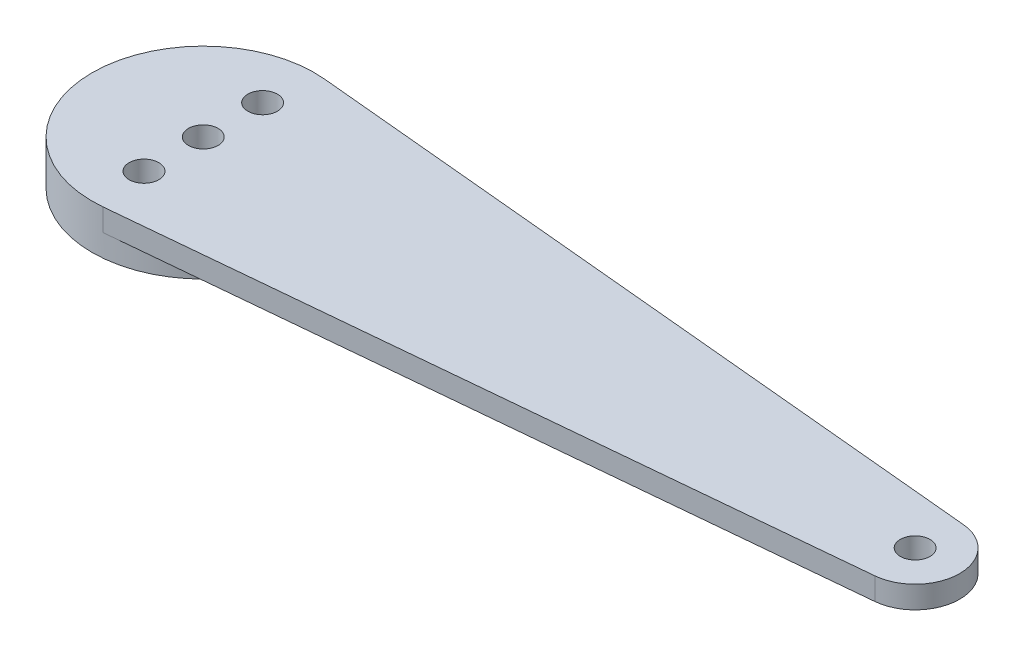
from build123d import *

# Parameters (mm, degrees)
SKETCH1_R           = 2
BOSS_EXTRUDE1_DEPTH = 3
BOSS_EXTRUDE2_START = -3
SKETCH1_3_R         = 2
BOSS_EXTRUDE2_DEPTH = 3


with BuildPart() as part:
    # Sketch1 → Boss-Extrude1 (new body)
    with BuildSketch(Plane(origin=(0, 0, 0), x_dir=(1, 0, 0), z_dir=(0, 1, 0))):
        with BuildLine():
            ThreePointArc((0.5625, -5.973574621), (6, 0), (0.5625, 5.973574621))
            Line((0.5625, 5.973574621), (-94.59375, 14.933936552))
            ThreePointArc((-94.59375, 14.933936552), (-111, 0), (-94.59375, -14.933936552))
            Line((-94.59375, -14.933936552), (0.5625, -5.973574621))
        make_face()
        Circle(SKETCH1_R, mode=Mode.SUBTRACT)
        with Locations((-96, 0)):
            Circle(SKETCH1_R, mode=Mode.SUBTRACT)
        with Locations((-96, 8)):
            Circle(SKETCH1_R, mode=Mode.SUBTRACT)
        with Locations((-96, -8)):
            Circle(SKETCH1_R, mode=Mode.SUBTRACT)
    extrude(amount=BOSS_EXTRUDE1_DEPTH)

    # Sketch1_3 → Boss-Extrude2 (add)
    with BuildSketch(Plane(origin=(0, 0, 0), x_dir=(1, 0, 0), z_dir=(0, 1, 0)).offset(BOSS_EXTRUDE2_START)):
        with BuildLine():
            ThreePointArc((-81, 0), (-84.907350407, 10.097184013), (-94.59375, 14.933936552))
            ThreePointArc((-94.59375, 14.933936552), (-111, 0), (-94.59375, -14.933936552))
            ThreePointArc((-94.59375, -14.933936552), (-84.907350407, -10.097184013), (-81, 0))
        make_face()
        with Locations((-96, -8)):
            Circle(SKETCH1_3_R, mode=Mode.SUBTRACT)
        with Locations((-96, 0)):
            Circle(SKETCH1_3_R, mode=Mode.SUBTRACT)
        with Locations((-96, 8)):
            Circle(SKETCH1_3_R, mode=Mode.SUBTRACT)
    extrude(amount=BOSS_EXTRUDE2_DEPTH)


solid = part.part
